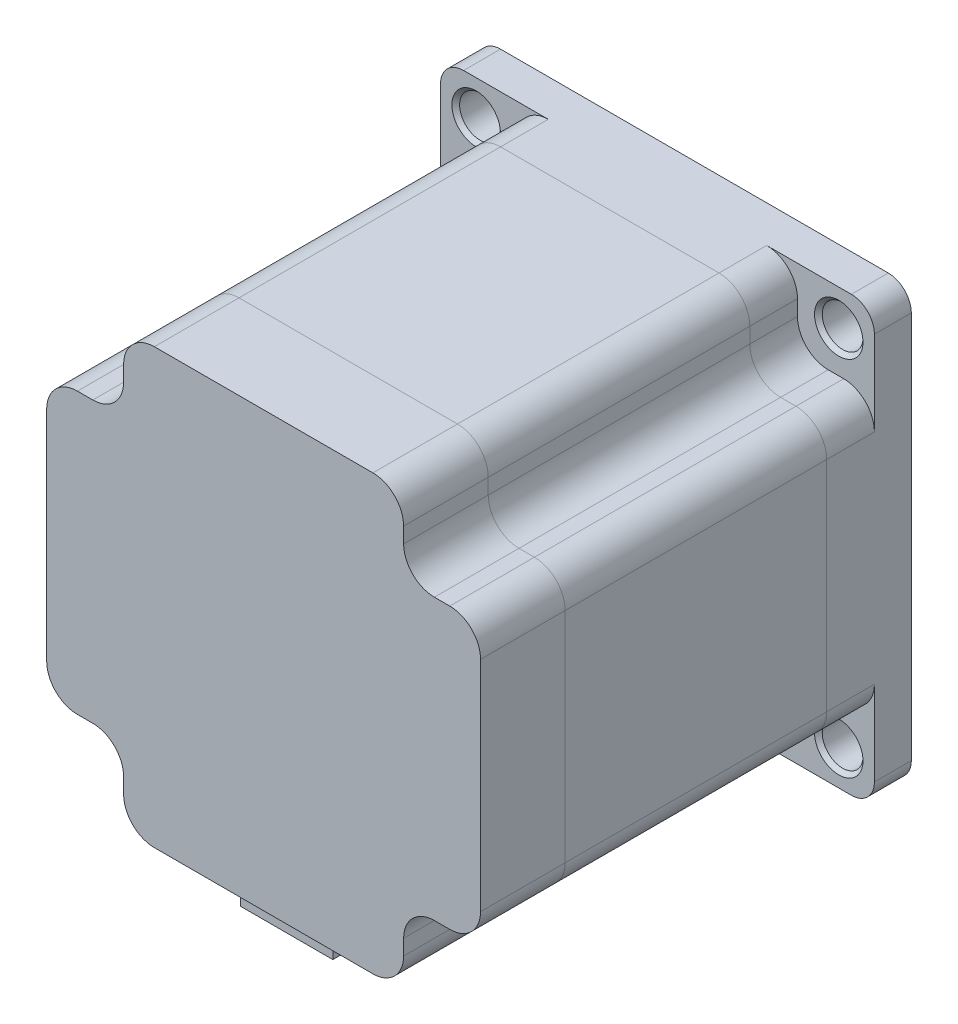
from build123d import *

# Parameters (mm, degrees)
SKETCH_1_W                  = 56.4
SKETCH_1_H                  = 56.4
EXTRUDE_1_DEPTH             = 11
SKETCH_2_W                  = 56.4
SKETCH_2_H                  = 56.4
EXTRUDE_2_DEPTH             = 34
SKETCH_3_W                  = 56.4
SKETCH_3_H                  = 56.4
EXTRUDE_3_DEPTH             = 11
SKETCH_4_R                  = 19.05
EXTRUDE_4_DEPTH             = 1.6
SKETCH_5_R                  = 5
CUT_EXTRUDE_1_DEPTH         = 5
SKETCH_6_R                  = 3.175
EXTRUDE_5_DEPTH             = 25.4
CUT_EXTRUDE_2_DEPTH         = 20
SKETCH_8_W                  = 10
SKETCH_8_H                  = 10
CUT_EXTRUDE_3_DEPTH         = 51.2
PATTERN_CIRCULAR_1_COUNT    = 4
SKETCH_11_W                 = 2.65
SKETCH_11_H                 = 26.8
HOLE_WIZARD_M5_1_AT_2_COUNT = 2
HOLE_WIZARD_M5_1_AT_2_PITCH = 66.66602733
HOLE_WIZARD_M5_1_AT_3_COUNT = 2
HOLE_WIZARD_M5_1_AT_3_PITCH = 47.14
HOLE_WIZARD_M5_1_AT_4_COUNT = 2
HOLE_WIZARD_M5_1_AT_4_PITCH = 47.14
CHAMFER_1_SIZE              = 0.5
FILLET_1_R                  = 3
FILLET_2_R                  = 4
FILLET_3_R                  = 4
FILLET_4_R                  = 4
SKETCH_12_W                 = 12
SKETCH_12_H                 = 5
EXTRUDE_6_DEPTH             = 4
SKETCH_13_R                 = 0.8
EXTRUDE_7_DEPTH             = 10
PATTERN_LINEAR_1_COUNT      = 3
PATTERN_LINEAR_1_PITCH      = 3
PATTERN_LINEAR_1_COL_COUNT  = 2
PATTERN_LINEAR_1_COL_PITCH  = 3


with BuildPart() as part:
    # Sketch 1 → Extrude 1 (new body)
    with BuildSketch(Plane.XY):
        Rectangle(SKETCH_1_W, SKETCH_1_H)
    extrude(amount=EXTRUDE_1_DEPTH)

    # Sketch 4 → Extrude 4 (add)
    with BuildSketch(Plane(origin=(0, 0, 0), x_dir=(-1, 0, 0), z_dir=(0, 0, -1))):
        Circle(SKETCH_4_R)
    extrude(amount=EXTRUDE_4_DEPTH)

    # Sketch 5 → Cut-Extrude 1 (cut)
    with BuildSketch(Plane(origin=(0, 0, -1.6), x_dir=(-1, 0, 0), z_dir=(0, 0, -1))):
        Circle(SKETCH_5_R)
    extrude(amount=-CUT_EXTRUDE_1_DEPTH, mode=Mode.SUBTRACT)


with BuildPart() as body_2:
    # Sketch 2 → Extrude 2 (new body)
    with BuildSketch(Plane.XY.offset(11)):
        Rectangle(SKETCH_2_W, SKETCH_2_H)
    extrude(amount=EXTRUDE_2_DEPTH)


with BuildPart() as body_3:
    # Sketch 3 → Extrude 3 (new body)
    with BuildSketch(Plane.XY.offset(45)):
        Rectangle(SKETCH_3_W, SKETCH_3_H)
    extrude(amount=EXTRUDE_3_DEPTH)


with BuildPart() as body_4:
    # Sketch 6 → Extrude 5 (new body)
    with BuildSketch(Plane(origin=(0, 0, 3.4), x_dir=(-1, 0, 0), z_dir=(0, 0, -1))):
        Circle(SKETCH_6_R)
    extrude(amount=EXTRUDE_5_DEPTH)

    # Sketch 7 → Cut-Extrude 2 (cut)
    with BuildSketch(Plane(origin=(0, 0, -22), x_dir=(-1, 0, 0), z_dir=(0, 0, -1))):
        with BuildLine():
            Line((-1.710263138, 2.675), (1.710263138, 2.675))
            ThreePointArc((1.710263138, 2.675), (0, 3.175), (-1.710263138, 2.675))
        make_face()
    extrude(amount=-CUT_EXTRUDE_2_DEPTH, mode=Mode.SUBTRACT)


with BuildPart() as cut_extrude_3_tool:
    # Sketch 8 → Cut-Extrude 3 (new body)
    with BuildSketch(Plane.XY.offset(56)):
        with Locations((23.2, 23.2)):
            Rectangle(SKETCH_8_W, SKETCH_8_H)
    cut_extrude_3 = extrude(amount=-CUT_EXTRUDE_3_DEPTH)


with BuildPart() as part_1:
    add(part.part)

    # Cut-Extrude 3: cut by cut_extrude_3_tool
    add(cut_extrude_3_tool.part, mode=Mode.SUBTRACT)


with BuildPart() as body_2_1:
    add(body_2.part)

    # Cut-Extrude 3: cut by cut_extrude_3_tool
    add(cut_extrude_3_tool.part, mode=Mode.SUBTRACT)


with BuildPart() as body_3_1:
    add(body_3.part)

    # Cut-Extrude 3: cut by cut_extrude_3_tool
    add(cut_extrude_3_tool.part, mode=Mode.SUBTRACT)


with BuildPart() as pattern_circular_1_tool:
    # Pattern Circular 1: Cut-Extrude 3 ×4 about axis
    pattern_circular_1_axis = Axis((0, 0, 0), (0, 0, 1))
    for i in range(1, PATTERN_CIRCULAR_1_COUNT):
        add(cut_extrude_3.rotate(pattern_circular_1_axis, i * 360 / PATTERN_CIRCULAR_1_COUNT))


with BuildPart() as part_2:
    add(part_1.part)

    # Pattern Circular 1: cut by pattern_circular_1_tool
    add(pattern_circular_1_tool.part, mode=Mode.SUBTRACT)

    # Sketch 11 → Hole Wizard M5 _1 (revolve, cut)
    with BuildSketch(Plane(origin=(23.57, 23.57, 4.8), x_dir=(0, -1, 0), z_dir=(1, 0, 0))):
        with Locations((1.325, 13.4)):
            Rectangle(SKETCH_11_W, SKETCH_11_H)
    hole_wizard_m5_1 = revolve(axis=Axis((23.57, 23.57, 11.15), (0, 0, -1)), mode=Mode.SUBTRACT)

    # Hole Wizard M5 _1 at 2: Hole Wizard M5 _1 ×2
    with Locations(*[Vector(-0.707106781, -0.707106781, 0) * (i * HOLE_WIZARD_M5_1_AT_2_PITCH) for i in range(1, HOLE_WIZARD_M5_1_AT_2_COUNT)]):
        add(hole_wizard_m5_1, mode=Mode.SUBTRACT)

    # Hole Wizard M5 _1 at 3: Hole Wizard M5 _1 ×2
    with Locations(*[(-i * HOLE_WIZARD_M5_1_AT_3_PITCH, 0, 0) for i in range(1, HOLE_WIZARD_M5_1_AT_3_COUNT)]):
        add(hole_wizard_m5_1, mode=Mode.SUBTRACT)

    # Hole Wizard M5 _1 at 4: Hole Wizard M5 _1 ×2
    with Locations(*[(0, -i * HOLE_WIZARD_M5_1_AT_4_PITCH, 0) for i in range(1, HOLE_WIZARD_M5_1_AT_4_COUNT)]):
        add(hole_wizard_m5_1, mode=Mode.SUBTRACT)

    # Chamfer 1
    chamfer_1_edges = [part_2.edges().sort_by_distance(p)[0] for p in [
        (23.57, -20.92, 0),
        (23.57, -20.92, 4.8),
        (-23.57, 26.22, 0),
        (-23.57, 26.22, 4.8),
        (-23.57, -20.92, 0),
        (-23.57, -20.92, 4.8),
        (23.57, 26.22, 0),
        (23.57, 26.22, 4.8),
    ]]
    chamfer(chamfer_1_edges, length=CHAMFER_1_SIZE)

    # Fillet 1
    fillet_1_edges = [part_2.edges().sort_by_distance(p)[0] for p in [
        (28.2, 28.2, 2.4),
        (28.2, -28.2, 2.4),
        (-28.2, -28.2, 2.4),
        (-28.2, 28.2, 2.4),
    ]]
    fillet(fillet_1_edges, radius=FILLET_1_R)

    # Fillet 2
    fillet_2_edges = [part_2.edges().sort_by_distance(p)[0] for p in [
        (18.2, 28.2, 7.9),
        (18.2, 18.2, 7.9),
        (28.2, 18.2, 7.9),
        (28.2, -18.2, 7.9),
        (18.2, -18.2, 7.9),
        (18.2, -28.2, 7.9),
        (-18.2, -28.2, 7.9),
        (-18.2, -18.2, 7.9),
        (-28.2, -18.2, 7.9),
        (-28.2, 18.2, 7.9),
        (-18.2, 18.2, 7.9),
        (-18.2, 28.2, 7.9),
    ]]
    fillet(fillet_2_edges, radius=FILLET_2_R)


with BuildPart() as body_2_2:
    add(body_2_1.part)

    # Pattern Circular 1: cut by pattern_circular_1_tool
    add(pattern_circular_1_tool.part, mode=Mode.SUBTRACT)

    # Fillet 3
    fillet_3_edges = [body_2_2.edges().sort_by_distance(p)[0] for p in [
        (18.2, 28.2, 28),
        (18.2, 18.2, 28),
        (28.2, 18.2, 28),
        (28.2, -18.2, 28),
        (18.2, -18.2, 28),
        (18.2, -28.2, 28),
        (-18.2, -28.2, 28),
        (-18.2, -18.2, 28),
        (-28.2, -18.2, 28),
        (-28.2, 18.2, 28),
        (-18.2, 18.2, 28),
        (-18.2, 28.2, 28),
    ]]
    fillet(fillet_3_edges, radius=FILLET_3_R)


with BuildPart() as body_3_2:
    add(body_3_1.part)

    # Pattern Circular 1: cut by pattern_circular_1_tool
    add(pattern_circular_1_tool.part, mode=Mode.SUBTRACT)

    # Fillet 4
    fillet_4_edges = [body_3_2.edges().sort_by_distance(p)[0] for p in [
        (18.2, 28.2, 50.5),
        (18.2, 18.2, 50.5),
        (28.2, 18.2, 50.5),
        (28.2, -18.2, 50.5),
        (18.2, -18.2, 50.5),
        (18.2, -28.2, 50.5),
        (-18.2, -28.2, 50.5),
        (-18.2, -18.2, 50.5),
        (-28.2, -18.2, 50.5),
        (-28.2, 18.2, 50.5),
        (-18.2, 18.2, 50.5),
        (-18.2, 28.2, 50.5),
    ]]
    fillet(fillet_4_edges, radius=FILLET_4_R)


with BuildPart() as body_5:
    # Sketch 12 → Extrude 6 (new body)
    with BuildSketch(Plane.XZ.offset(28.2)):
        with Locations((0, 50.5)):
            Rectangle(SKETCH_12_W, SKETCH_12_H)
    extrude(amount=EXTRUDE_6_DEPTH)


with BuildPart() as body_6:
    # Sketch 13 → Extrude 7 (new body)
    with BuildSketch(Plane(origin=(0, 0, 48), x_dir=(-1, 0, 0), z_dir=(0, 0, -1))):
        with Locations((1.5, -30.2)):
            Circle(SKETCH_13_R)
    extrude_7 = extrude(amount=EXTRUDE_7_DEPTH)


with BuildPart() as pattern_linear_1_1:
    # Pattern Linear 1: Extrude 7 ×3
    with Locations(*[(i * PATTERN_LINEAR_1_PITCH, 0, 0) for i in range(1, PATTERN_LINEAR_1_COUNT)]):
        add(extrude_7)


with BuildPart() as pattern_linear_1_col_1:
    # Pattern Linear 1 col: Extrude 7 ×2
    with Locations(*[(-i * PATTERN_LINEAR_1_COL_PITCH, 0, 0) for i in range(1, PATTERN_LINEAR_1_COL_COUNT)]):
        add(extrude_7)


solid = Compound([body_4.part, part_2.part, body_2_2.part, body_3_2.part, body_5.part, body_6.part, pattern_linear_1_1.part, pattern_linear_1_col_1.part])
